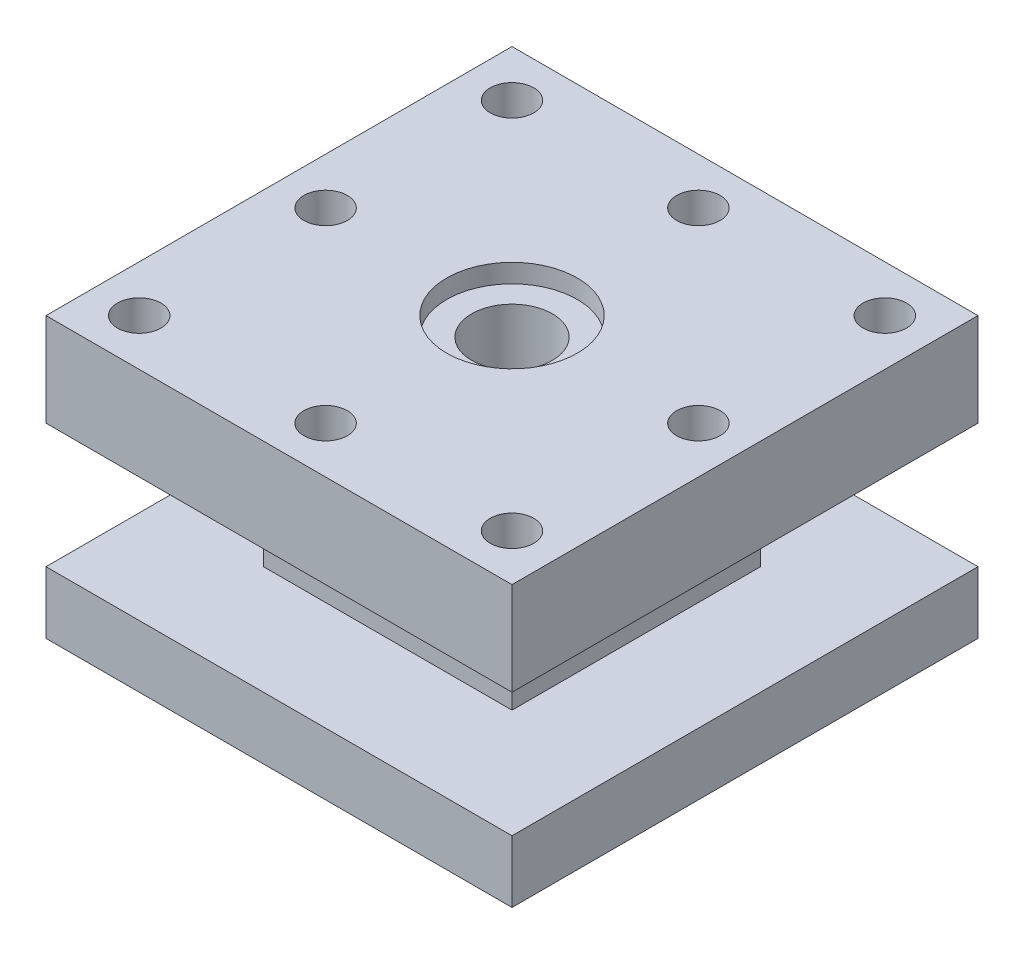
from build123d import *

# Parameters (mm, degrees)
SKETCH2_W           = 150
SKETCH2_H           = 150
BOSS_EXTRUDE1_DEPTH = 20
SKETCH4_W           = 80
SKETCH4_H           = 80
BOSS_EXTRUDE2_DEPTH = 40
SKETCH5_W           = 150
SKETCH5_H           = 150
BOSS_EXTRUDE3_DEPTH = 30
SKETCH6_R           = 13
CUT_EXTRUDE1_DEPTH  = 168
SKETCH7_R           = 21
CUT_EXTRUDE2_DEPTH  = 6
SKETCH8_R           = 32
CUT_EXTRUDE3_DEPTH  = 12
SKETCH9_R           = 7
CUT_EXTRUDE4_DEPTH  = 52


with BuildPart() as part:
    # Sketch2 → Boss-Extrude1 (new body)
    with BuildSketch(Plane(origin=(0, 0, 0), x_dir=(1, 0, 0), z_dir=(0, 1, 0))):
        with Locations((75, 75)):
            Rectangle(SKETCH2_W, SKETCH2_H)
    extrude(amount=BOSS_EXTRUDE1_DEPTH)

    # Sketch4 → Boss-Extrude2 (add)
    with BuildSketch(Plane(origin=(0, 20, 0), x_dir=(1, 0, 0), z_dir=(0, 1, 0))):
        with Locations((75, 75)):
            Rectangle(SKETCH4_W, SKETCH4_H)
    extrude(amount=BOSS_EXTRUDE2_DEPTH)

    # Sketch5 → Boss-Extrude3 (add)
    with BuildSketch(Plane(origin=(0, 60, 0), x_dir=(1, 0, 0), z_dir=(0, 1, 0))):
        with Locations((75, 75)):
            Rectangle(SKETCH5_W, SKETCH5_H)
    extrude(amount=BOSS_EXTRUDE3_DEPTH)

    # Sketch6 → Cut-Extrude1 (cut)
    with BuildSketch(Plane(origin=(0, 90, 0), x_dir=(1, 0, 0), z_dir=(0, 1, 0))):
        with Locations((75, 75)):
            Circle(SKETCH6_R)
    extrude(amount=-CUT_EXTRUDE1_DEPTH, mode=Mode.SUBTRACT)

    # Sketch7 → Cut-Extrude2 (cut)
    with BuildSketch(Plane(origin=(0, 90, 0), x_dir=(1, 0, 0), z_dir=(0, 1, 0))):
        with Locations((75, 75)):
            Circle(SKETCH7_R)
    extrude(amount=-CUT_EXTRUDE2_DEPTH, mode=Mode.SUBTRACT)

    # Sketch8 → Cut-Extrude3 (cut)
    with BuildSketch(Plane.XZ):
        with Locations((75, -75)):
            Circle(SKETCH8_R)
    extrude(amount=-CUT_EXTRUDE3_DEPTH, mode=Mode.SUBTRACT)

    # Sketch9 → Cut-Extrude4 (cut)
    with BuildSketch(Plane(origin=(0, 90, 0), x_dir=(1, 0, 0), z_dir=(0, 1, 0))):
        with Locations((75, 135)):
            Circle(SKETCH9_R)
        with Locations((15, 75)):
            Circle(SKETCH9_R)
        with Locations((75, 15)):
            Circle(SKETCH9_R)
        with Locations((135, 75)):
            Circle(SKETCH9_R)
        with Locations((15, 135)):
            Circle(SKETCH9_R)
        with Locations((135, 135)):
            Circle(SKETCH9_R)
        with Locations((135, 15)):
            Circle(SKETCH9_R)
        with Locations((15, 15)):
            Circle(SKETCH9_R)
    extrude(amount=-CUT_EXTRUDE4_DEPTH, mode=Mode.SUBTRACT)


solid = part.part
